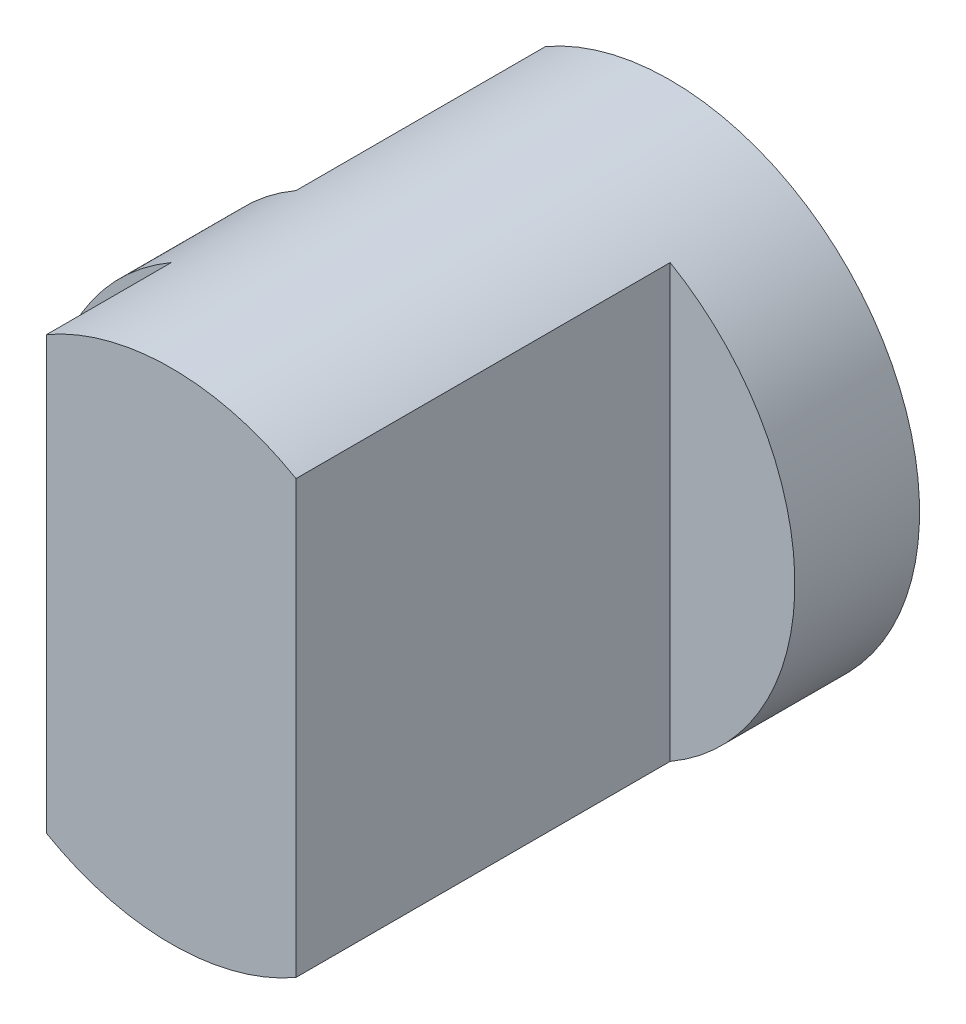
from build123d import *

# Parameters (mm, degrees)
SKETCH1_R           = 2
BOSS_EXTRUDE1_DEPTH = 4
SKETCH2_W           = 1
SKETCH2_H           = 3
SKETCH2_H_2         = 1
SKETCH2_H_3         = 2
CUT_EXTRUDE1_DEPTH  = 5


with BuildPart() as part:
    # Sketch1 → Boss-Extrude1 (new body)
    with BuildSketch(Plane.XY):
        Circle(SKETCH1_R)
    extrude(amount=BOSS_EXTRUDE1_DEPTH)

    # Sketch2 → Cut-Extrude1 (cut, symmetric)
    with BuildSketch(Plane(origin=(0, 0, 0), x_dir=(1, 0, 0), z_dir=(0, 1, 0))):
        with Locations((1.5, -2.5)):
            Rectangle(SKETCH2_W, SKETCH2_H)
        with Locations((-1.5, -3.5)):
            Rectangle(SKETCH2_W, SKETCH2_H_2)
        with Locations((-1.5, -1)):
            Rectangle(SKETCH2_W, SKETCH2_H_3)
    extrude(amount=CUT_EXTRUDE1_DEPTH, both=True, mode=Mode.SUBTRACT)


solid = part.part
